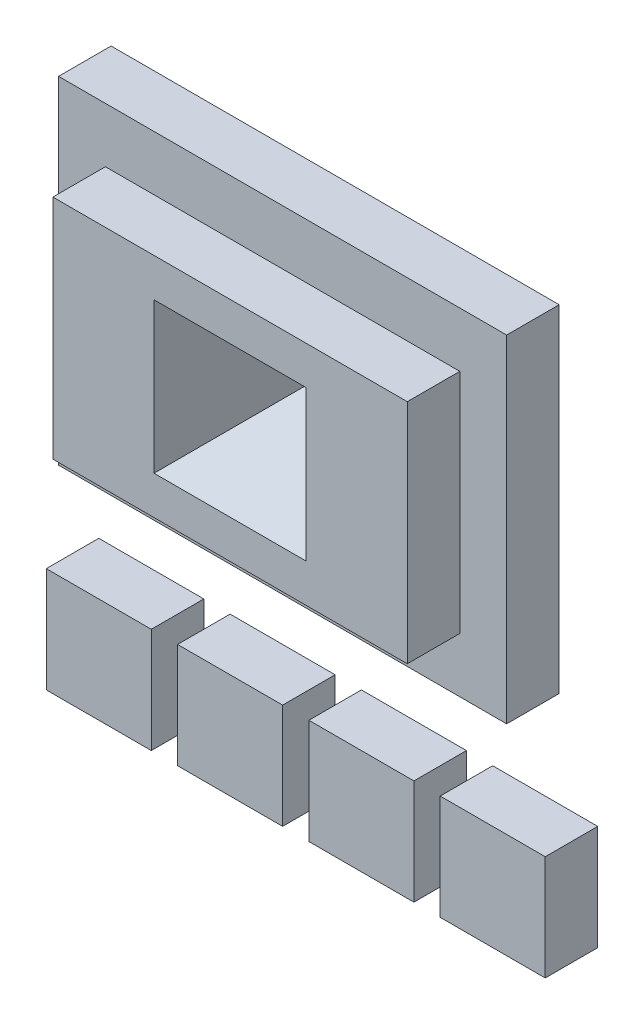
from build123d import *

# Parameters (mm, degrees)
SKETCH1_W             = 20
SKETCH1_H             = 20
BOSS_EXTRUDE1_DEPTH   = 10
BOSS_EXTRUDE1_2_DEPTH = 10
BOSS_EXTRUDE1_3_DEPTH = 10
BOSS_EXTRUDE1_4_DEPTH = 10
SKETCH1_W_2           = 85.312438272
SKETCH1_H_2           = 64.113648737
BOSS_EXTRUDE1_5_DEPTH = 10
SKETCH4_W             = 67.476401288
SKETCH4_H             = 43.220291255
BOSS_EXTRUDE2_DEPTH   = 10
SKETCH5_W             = 28.970393718
SKETCH5_H             = 28.604205767
CUT_EXTRUDE1_DEPTH    = 20
CUT_EXTRUDE1_TAPER    = 25


with BuildPart() as part:
    # Sketch1 → Boss-Extrude1 (new body)
    with BuildSketch(Plane.XY):
        with Locations((25, 0)):
            Rectangle(SKETCH1_W, SKETCH1_H)
    extrude(amount=BOSS_EXTRUDE1_DEPTH)


with BuildPart() as body_2:
    # Sketch1 → Boss-Extrude1 2 (new body)
    with BuildSketch(Plane.XY):
        Rectangle(SKETCH1_W, SKETCH1_H)
    extrude(amount=BOSS_EXTRUDE1_2_DEPTH)


with BuildPart() as body_3:
    # Sketch1 → Boss-Extrude1 3 (new body)
    with BuildSketch(Plane.XY):
        with Locations((50, 0)):
            Rectangle(SKETCH1_W, SKETCH1_H)
    extrude(amount=BOSS_EXTRUDE1_3_DEPTH)


with BuildPart() as body_4:
    # Sketch1 → Boss-Extrude1 4 (new body)
    with BuildSketch(Plane.XY):
        with Locations((75, 0)):
            Rectangle(SKETCH1_W, SKETCH1_H)
    extrude(amount=BOSS_EXTRUDE1_4_DEPTH)


with BuildPart() as body_5:
    # Sketch1 → Boss-Extrude1 5 (new body)
    with BuildSketch(Plane.XY):
        with Locations((35, 60.288380117)):
            Rectangle(SKETCH1_W_2, SKETCH1_H_2)
    extrude(amount=BOSS_EXTRUDE1_5_DEPTH)

    # Sketch4 → Boss-Extrude2 (add)
    with BuildSketch(Plane.XY.offset(10)):
        with Locations((35, 60.288380117)):
            Rectangle(SKETCH4_W, SKETCH4_H)
    extrude(amount=BOSS_EXTRUDE2_DEPTH)

    # Sketch5 → Cut-Extrude1 (cut)
    with BuildSketch(Plane.XY.offset(20)):
        with Locations((35, 60.288380118)):
            Rectangle(SKETCH5_W, SKETCH5_H)
    extrude(amount=-CUT_EXTRUDE1_DEPTH, taper=CUT_EXTRUDE1_TAPER, mode=Mode.SUBTRACT)


solid = Compound([part.part, body_2.part, body_3.part, body_4.part, body_5.part])
